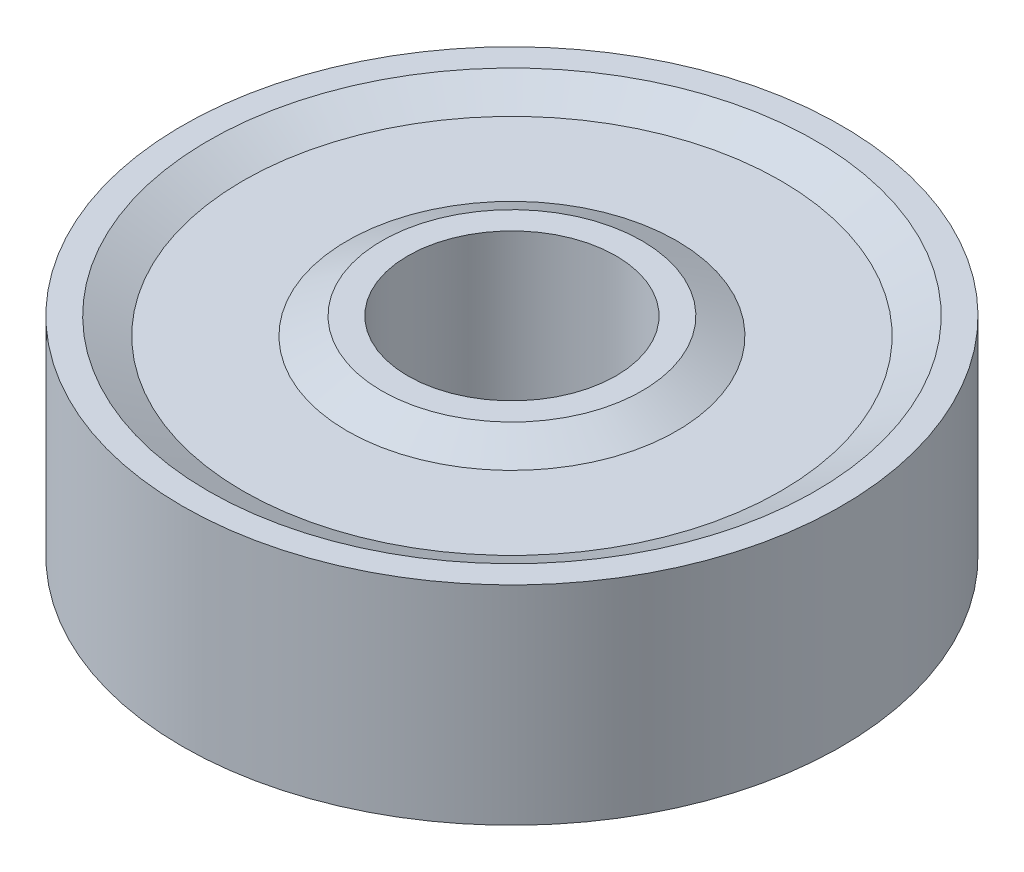
from build123d import *

# Parameters (mm, degrees)
SKETCH1_R           = 9.5
SKETCH1_R_2         = 3
BOSS_EXTRUDE1_DEPTH = 6


with BuildPart() as part:
    # Sketch1 → Boss-Extrude1 (new body)
    with BuildSketch(Plane(origin=(0, 0, 0), x_dir=(1, 0, 0), z_dir=(0, 1, 0))):
        Circle(SKETCH1_R)
        Circle(SKETCH1_R_2, mode=Mode.SUBTRACT)
    extrude(amount=BOSS_EXTRUDE1_DEPTH)

    # Sketch2 → Cut-Revolve1 (revolve, cut)
    with BuildSketch(Plane.XY):
        Polygon((-3.75, 6), (-4.75, 5.5), (-7.75, 5.5), (-8.75, 6), align=None)
        Polygon((-8.75, 0), (-3.75, 0), (-4.75, 0.5), (-7.75, 0.5), align=None)
    revolve(axis=Axis((0, 6, 0), (0, -1, 0)), mode=Mode.SUBTRACT)


solid = part.part
